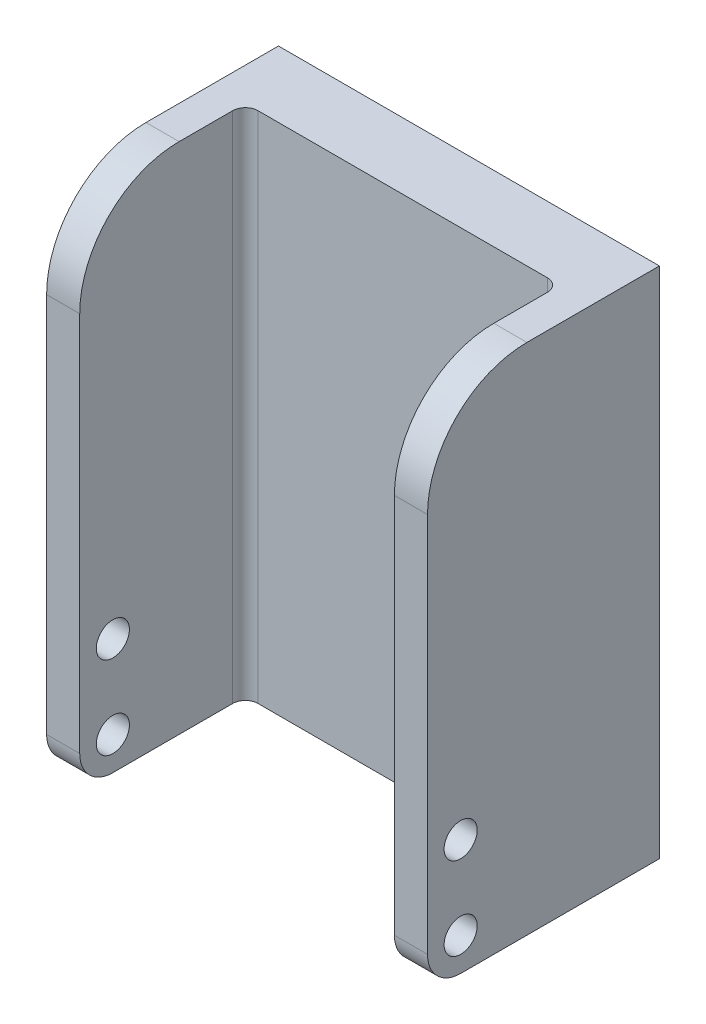
from build123d import *

# Parameters (mm, degrees)
SKETCH1_W           = 23
SKETCH1_H           = 31
BOSS_EXTRUDE1_DEPTH = 4
SKETCH2_W           = 10
SKETCH2_H           = 31
BOSS_EXTRUDE2_DEPTH = 2
SKETCH3_R           = 1
CUT_EXTRUDE1_DEPTH  = 24
FILLET1_R           = 2
FILLET2_R           = 6
FILLET3_R           = 0.762


with BuildPart() as part:
    # Sketch1 → Boss-Extrude1 (new body)
    with BuildSketch(Plane.XY):
        Rectangle(SKETCH1_W, SKETCH1_H)
    extrude(amount=BOSS_EXTRUDE1_DEPTH)

    # Sketch2 → Boss-Extrude2 (add)
    with BuildSketch(Plane(origin=(11.5, 0, 0), x_dir=(0, 0, -1), z_dir=(1, 0, 0))):
        with Locations((-9, 0)):
            Rectangle(SKETCH2_W, SKETCH2_H)
    boss_extrude2 = extrude(amount=-BOSS_EXTRUDE2_DEPTH)

    # Mirror1: Boss-Extrude2 across plane
    add(boss_extrude2.mirror(Plane(origin=(0, 0, 0), x_dir=(0, 0, 1), z_dir=(1, 0, 0))))

    # Sketch3 → Cut-Extrude1 (cut, through all)
    with BuildSketch(Plane(origin=(11.5, 0, 0), x_dir=(0, 0, -1), z_dir=(1, 0, 0))):
        with Locations((-12, -8.5)):
            Circle(SKETCH3_R)
        with Locations((-12, -13.5)):
            Circle(SKETCH3_R)
    extrude(amount=-CUT_EXTRUDE1_DEPTH, mode=Mode.SUBTRACT)

    # Fillet1
    fillet1_edges = [part.edges().sort_by_distance(p)[0] for p in [
        (10.5, -15.5, 14),
        (-10.5, -15.5, 14),
    ]]
    fillet(fillet1_edges, radius=FILLET1_R)

    # Fillet2
    fillet2_edges = [part.edges().sort_by_distance(p)[0] for p in [
        (10.5, 15.5, 14),
        (-10.5, 15.5, 14),
    ]]
    fillet(fillet2_edges, radius=FILLET2_R)

    # Fillet3
    fillet3_edges = [part.edges().sort_by_distance(p)[0] for p in [
        (9.5, 0, 4),
        (-9.5, 0, 4),
    ]]
    fillet(fillet3_edges, radius=FILLET3_R)


solid = part.part
